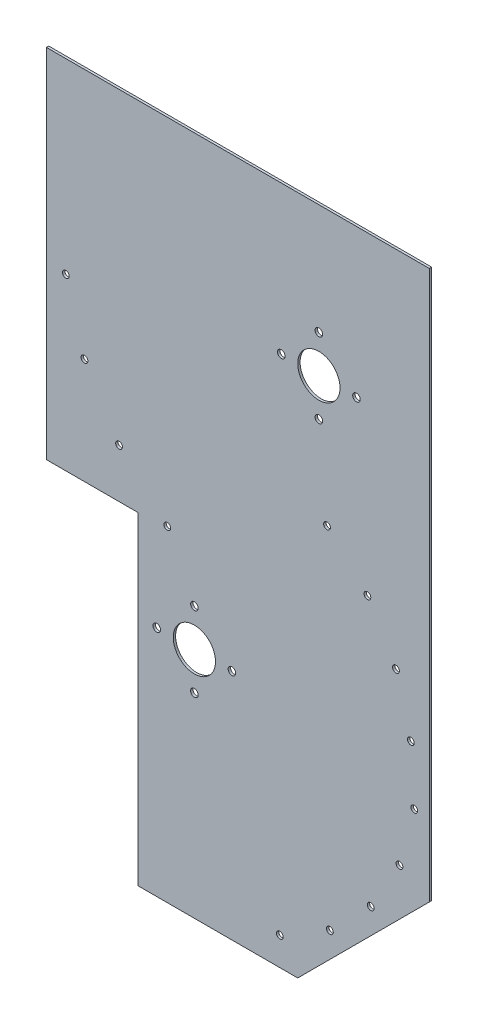
from build123d import *

# Parameters (mm, degrees)
SKETCH1_R           = 2.5527
SKETCH1_R_2         = 14.2875
SKETCH1_R_3         = 2.286
BOSS_EXTRUDE1_DEPTH = 1.5875
SKETCH2_W           = 61.9125
SKETCH2_H           = 218.44
CUT_EXTRUDE1_DEPTH  = 2.5875
CHAMFER1_SIZE       = 88.9


with BuildPart() as part:
    # Sketch1 → Boss-Extrude1 (new body)
    with BuildSketch(Plane.XY):
        with BuildLine():
            Line((-182.5625, -359.614215072), (74.6125, -359.614215072))
            Line((74.6125, -359.614215072), (74.6125, 100.125784928))
            Line((74.6125, 100.125784928), (-184.15, 100.125784928))
            Line((-184.15, 100.125784928), (-184.15, -323.589680411))
            ThreePointArc((-184.15, -323.589680411), (-183.358351266, -324.237998925), (-182.5625, -324.881151609))
            Line((-182.5625, -324.881151609), (-182.5625, -359.614215072))
        make_face()
        with Locations((-84.1375, -227.673915072)):
            Circle(SKETCH1_R, mode=Mode.SUBTRACT)
        with Locations((-109.5375, -202.273915072)):
            Circle(SKETCH1_R, mode=Mode.SUBTRACT)
        with Locations((-84.1375, -202.273915072)):
            Circle(SKETCH1_R_2, mode=Mode.SUBTRACT)
        with Locations((-84.1375, -176.873915072)):
            Circle(SKETCH1_R, mode=Mode.SUBTRACT)
        with Locations((-58.7375, -202.273915072)):
            Circle(SKETCH1_R, mode=Mode.SUBTRACT)
        with Locations((-26.369714503, -340.552266808)):
            Circle(SKETCH1_R_3, mode=Mode.SUBTRACT)
        with Locations((7.450966894, -320.88914315)):
            Circle(SKETCH1_R_3, mode=Mode.SUBTRACT)
        with Locations((35.030045629, -293.14258772)):
            Circle(SKETCH1_R_3, mode=Mode.SUBTRACT)
        with Locations((54.488053063, -259.203482417)):
            Circle(SKETCH1_R_3, mode=Mode.SUBTRACT)
        with Locations((64.498958145, -221.384721179)):
            Circle(SKETCH1_R_3, mode=Mode.SUBTRACT)
        with BuildLine():
            Line((73.025, -206.741987336), (73.025, -202.273915072))
            Line((73.025, -202.273915072), (73.025, -197.805842809))
            ThreePointArc((73.025, -197.805842809), (73.0885, -202.273915072), (73.025, -206.741987336))
        make_face(mode=Mode.SUBTRACT)
        with Locations((62.145886508, -182.799411028)):
            Circle(SKETCH1_R_3, mode=Mode.SUBTRACT)
        with Locations((-158.413638358, -69.463111493)):
            Circle(SKETCH1_R_3, mode=Mode.SUBTRACT)
        with Locations((-135.03744834, -108.096679976)):
            Circle(SKETCH1_R_3, mode=Mode.SUBTRACT)
        with Locations((-102.458679377, -139.363638358)):
            Circle(SKETCH1_R_3, mode=Mode.SUBTRACT)
        with Locations((-170.994200713, -26.095746755)):
            Circle(SKETCH1_R_3, mode=Mode.SUBTRACT)
        with Locations((5.529920705, -85.065386628)):
            Circle(SKETCH1_R_3, mode=Mode.SUBTRACT)
        with Locations((32.810376845, -112.26680659)):
            Circle(SKETCH1_R_3, mode=Mode.SUBTRACT)
        with Locations((52.121028445, -145.602062252)):
            Circle(SKETCH1_R_3, mode=Mode.SUBTRACT)
        with Locations((0, -25.4)):
            Circle(SKETCH1_R, mode=Mode.SUBTRACT)
        with Locations((-25.4, 0)):
            Circle(SKETCH1_R, mode=Mode.SUBTRACT)
        Circle(SKETCH1_R_2, mode=Mode.SUBTRACT)
        with Locations((0, 25.4)):
            Circle(SKETCH1_R, mode=Mode.SUBTRACT)
        with Locations((25.4, 0)):
            Circle(SKETCH1_R, mode=Mode.SUBTRACT)
    extrude(amount=BOSS_EXTRUDE1_DEPTH)

    # Sketch2 → Cut-Extrude1 (cut, through all)
    with BuildSketch(Plane.XY.offset(1.5875)):
        with Locations((-153.19375, -250.394215072)):
            Rectangle(SKETCH2_W, SKETCH2_H)
    extrude(amount=-CUT_EXTRUDE1_DEPTH, mode=Mode.SUBTRACT)

    # Chamfer1
    chamfer1_edges = [part.edges().sort_by_distance(p)[0] for p in [
        (74.6125, -359.614215072, 0.79375),
    ]]
    chamfer(chamfer1_edges, length=CHAMFER1_SIZE)


solid = part.part
